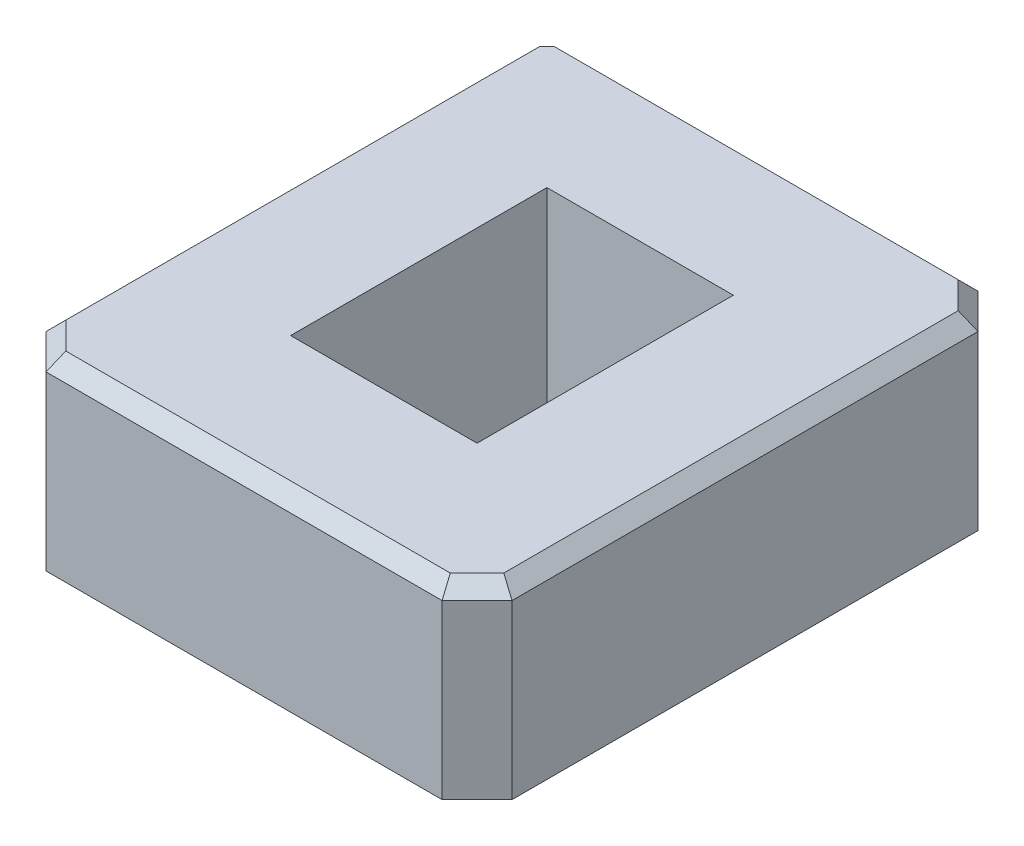
from build123d import *

# Parameters (mm, degrees)
SKETCH1_W           = 20
SKETCH1_H           = 23
SKETCH1_W_2         = 8
SKETCH1_H_2         = 11
BOSS_EXTRUDE1_DEPTH = 8
CHAMFER1_SIZE       = 1.5
CHAMFER2_SIZE       = 0.6


with BuildPart() as part:
    # Sketch1 → Boss-Extrude1 (new body)
    with BuildSketch(Plane(origin=(0, 0, 0), x_dir=(1, 0, 0), z_dir=(0, 1, 0))):
        Rectangle(SKETCH1_W, SKETCH1_H)
        Rectangle(SKETCH1_W_2, SKETCH1_H_2, mode=Mode.SUBTRACT)
    extrude(amount=BOSS_EXTRUDE1_DEPTH)

    # Chamfer1
    chamfer1_edges = [part.edges().sort_by_distance(p)[0] for p in [
        (-10, 4, -11.5),
        (10, 4, -11.5),
        (10, 4, 11.5),
        (-10, 4, 11.5),
    ]]
    chamfer(chamfer1_edges, length=CHAMFER1_SIZE)

    # Chamfer2
    chamfer2_edges = [part.edges().sort_by_distance(p)[0] for p in [
        (10, 8, 0),
        (0, 8, 11.5),
        (-10, 8, 0),
        (0, 8, -11.5),
        (-9.25, 8, 10.75),
        (9.25, 8, -10.75),
        (9.25, 8, 10.75),
    ]]
    chamfer(chamfer2_edges, length=CHAMFER2_SIZE)


solid = part.part
